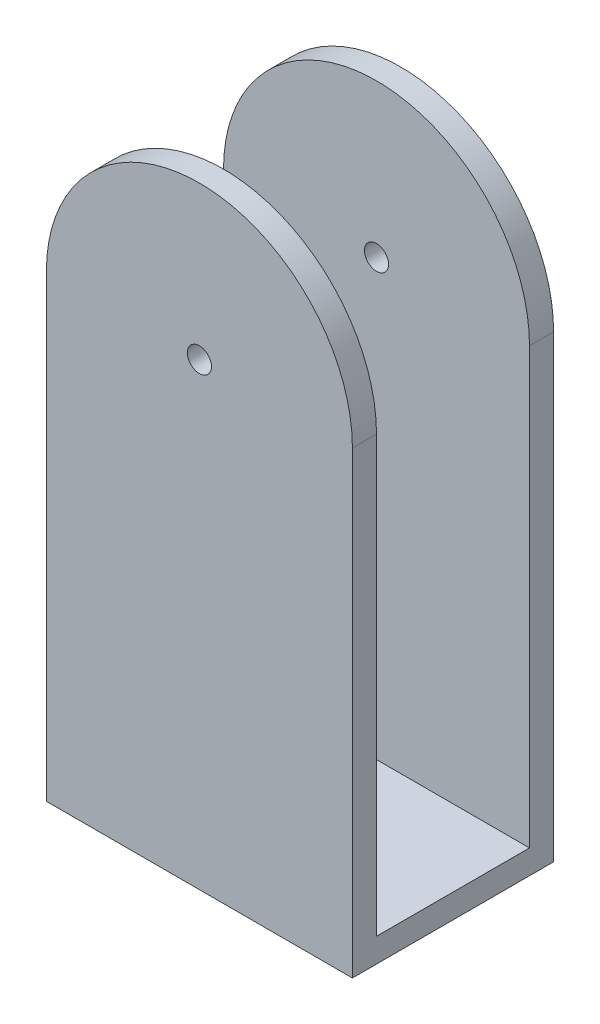
from build123d import *

# Parameters (mm, degrees)
SKETCH1_R           = 0.5
BOSS_EXTRUDE1_DEPTH = 1
SKETCH2_W           = 12.7
SKETCH2_H           = 1
BOSS_EXTRUDE2_DEPTH = 6.35
SKETCH3_R           = 0.5
BOSS_EXTRUDE3_DEPTH = 1


with BuildPart() as part:
    # Sketch1 → Boss-Extrude1 (new body)
    with BuildSketch(Plane.XY):
        with BuildLine():
            Line((0, 0), (0, 19.05))
            ThreePointArc((0, 19.05), (6.35, 25.4), (12.7, 19.05))
            Line((12.7, 19.05), (12.7, 0))
            Line((12.7, 0), (0, 0))
        make_face()
        with Locations((6.35, 19.05)):
            Circle(SKETCH1_R, mode=Mode.SUBTRACT)
    extrude(amount=BOSS_EXTRUDE1_DEPTH)

    # Sketch2 → Boss-Extrude2 (add)
    with BuildSketch(Plane.XY.offset(1)):
        with Locations((6.35, 0.5)):
            Rectangle(SKETCH2_W, SKETCH2_H)
    extrude(amount=BOSS_EXTRUDE2_DEPTH)

    # Sketch3 → Boss-Extrude3 (add)
    with BuildSketch(Plane.XY.offset(7.35)):
        with BuildLine():
            Line((0, 0), (12.7, 0))
            Line((12.7, 0), (12.7, 19.05))
            ThreePointArc((12.7, 19.05), (6.35, 25.4), (0, 19.05))
            Line((0, 19.05), (0, 0))
        make_face()
        with Locations((6.35, 19.05)):
            Circle(SKETCH3_R, mode=Mode.SUBTRACT)
    extrude(amount=BOSS_EXTRUDE3_DEPTH)


solid = part.part
